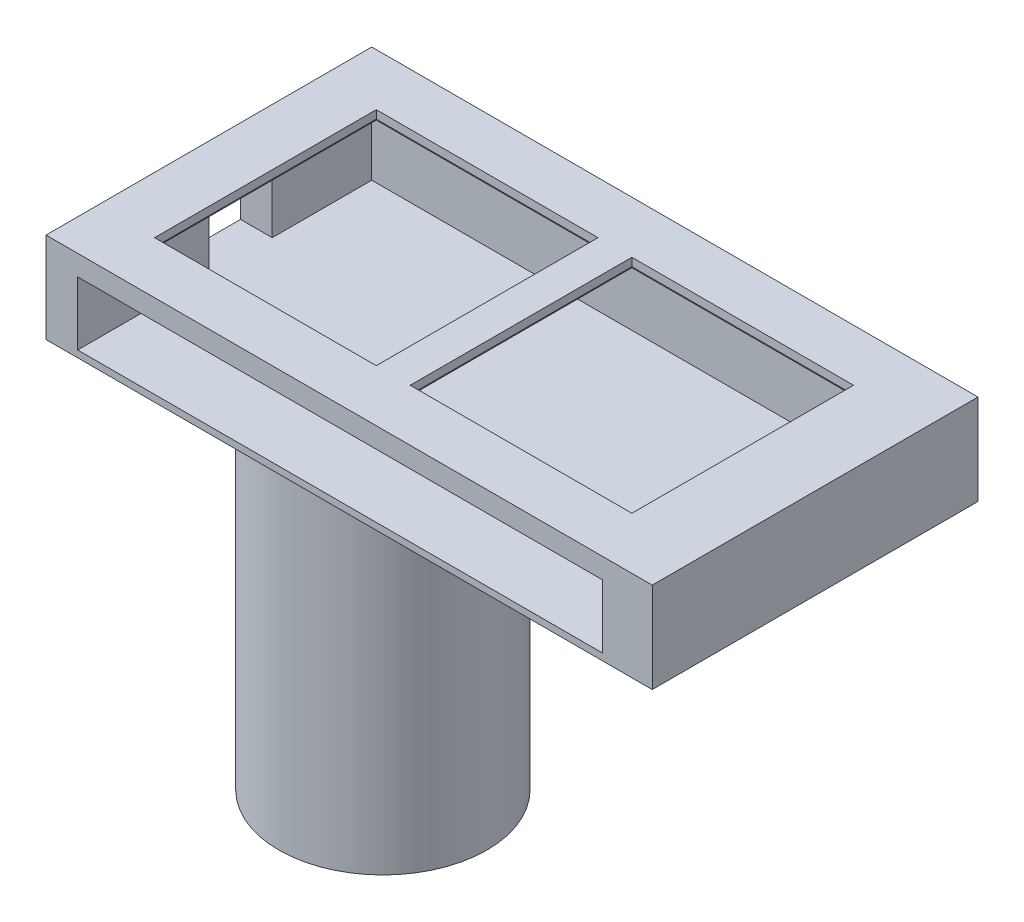
from build123d import *

# Parameters (mm, degrees)
MAIN_BODY_DEPTH     = 16
SKETCH8_W           = 134
SKETCH8_H           = 4
COVER_DEPTH         = 72
SKETCH20_W          = 116
SKETCH20_H          = 14
CRYSTAL_SLOT_DEPTH  = 65
SKETCH9_W           = 14
SKETCH9_H           = 14
SIPM_WINDOW_DEPTH   = 7
SKETCH10_R          = 23
SKETCH10_R_2        = 20
TUBE_ADAPTER_DEPTH  = 85
SKETCH21_W          = 54
SKETCH21_H          = 54
FILTER_SLOT_DEPTH   = 2.7
SKETCH24_W          = 49
SKETCH24_H          = 49
FILTER_WINDOW_DEPTH = 1.8
WIRE_SLOT_REACH     = 146
SKETCH25_W          = 25
SKETCH25_H          = 9


with BuildPart() as part:
    # Sketch5 → Main Body (new body)
    with BuildSketch(Plane(origin=(0, 0, 0), x_dir=(1, 0, 0), z_dir=(0, 1, 0))):
        Polygon((-134, 0), (-124, 0), (-1.95326153, 0), (0, 0), (0, 72), (-134, 72), align=None)
    extrude(amount=-MAIN_BODY_DEPTH)

    # Sketch8 → Cover (add)
    with BuildSketch(Plane.XY):
        with Locations((-67, -18)):
            Rectangle(SKETCH8_W, SKETCH8_H)
    extrude(amount=-COVER_DEPTH)

    # Sketch20 → Crystal Slot (cut)
    with BuildSketch(Plane.XY):
        with Locations((-69, -11.5)):
            Rectangle(SKETCH20_W, SKETCH20_H)
    extrude(amount=-CRYSTAL_SLOT_DEPTH, mode=Mode.SUBTRACT)

    # Sketch9 → SiPM Window (cut)
    with BuildSketch(Plane.ZY.offset(134)):
        with Locations((-36, -11.5)):
            Rectangle(SKETCH9_W, SKETCH9_H)
    extrude(amount=-SIPM_WINDOW_DEPTH, mode=Mode.SUBTRACT)

    # Sketch10 → Tube Adapter (add)
    with BuildSketch(Plane.XZ.offset(20)):
        with Locations((-95.536800003, -36)):
            Circle(SKETCH10_R)
        with Locations((-95.536800003, -36)):
            Circle(SKETCH10_R_2, mode=Mode.SUBTRACT)
    extrude(amount=TUBE_ADAPTER_DEPTH)

    # Sketch21 → Filter Slot (cut)
    with BuildSketch(Plane.XZ.offset(4.5)):
        with Locations((-40.5, -36)):
            Rectangle(SKETCH21_W, SKETCH21_H)
        with Locations((-97, -36)):
            Rectangle(SKETCH21_W, SKETCH21_H)
    extrude(amount=-FILTER_SLOT_DEPTH, mode=Mode.SUBTRACT)

    # Sketch24 → Filter Window (cut)
    with BuildSketch(Plane.XZ.offset(1.8)):
        with Locations((-40.5, -36)):
            Rectangle(SKETCH24_W, SKETCH24_H)
        with Locations((-97, -36)):
            Rectangle(SKETCH24_W, SKETCH24_H)
    extrude(amount=-FILTER_WINDOW_DEPTH, mode=Mode.SUBTRACT)

    # Sketch25 → Wire Slot (cut, up to next)
    with BuildSketch(Plane.ZY.offset(144), mode=Mode.PRIVATE) as wire_slot_sk1:
        with Locations((-36, -24.5)):
            Rectangle(SKETCH25_W, SKETCH25_H)
    wire_slot_tool1 = extrude(wire_slot_sk1.sketch, amount=-WIRE_SLOT_REACH, mode=Mode.PRIVATE) & part.part
    add(wire_slot_tool1.solids().sort_by_distance((-144, -24.5, -36))[0], mode=Mode.SUBTRACT)


solid = part.part
